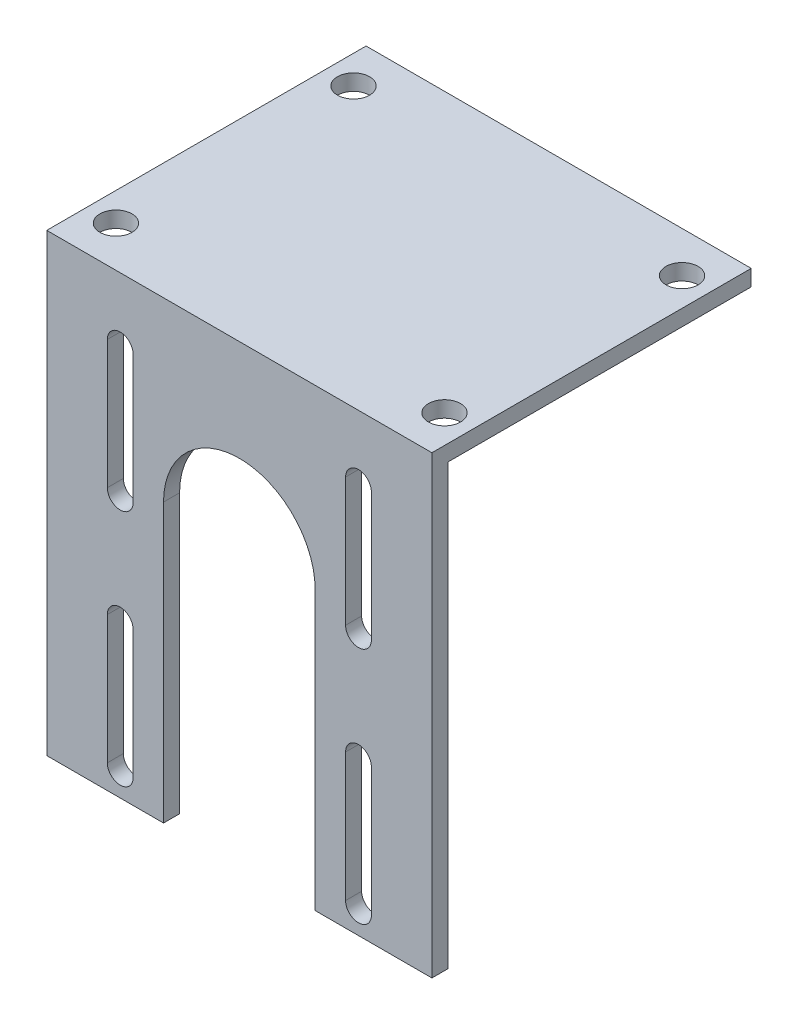
from build123d import *

# Parameters (mm, degrees)
SKETCH1_W           = 76.2
SKETCH1_H           = 100
BOSS_EXTRUDE1_DEPTH = 3.175
CUT_EXTRUDE2_REACH  = 5.175
SKETCH4_W           = 76.2
SKETCH4_H           = 3.175
BOSS_EXTRUDE2_DEPTH = 60
SKETCH5_R           = 3.175
CUT_EXTRUDE3_DEPTH  = 3.175
SKETCH6_W           = 76.2
SKETCH6_H           = 10
CUT_EXTRUDE4_DEPTH  = 64.175


with BuildPart() as part:
    # Sketch1 → Boss-Extrude1 (new body)
    with BuildSketch(Plane.XY):
        with Locations((38.1, -50)):
            Rectangle(SKETCH1_W, SKETCH1_H)
        with BuildLine():
            Line((17.08, -12.7), (17.08, -38.1))
            ThreePointArc((17.08, -38.1), (14.53, -40.65), (11.98, -38.1))
            Line((11.98, -38.1), (11.98, -12.7))
            ThreePointArc((11.98, -12.7), (14.53, -10.15), (17.08, -12.7))
        make_face(mode=Mode.SUBTRACT)
        with BuildLine():
            Line((59.12, -12.7), (59.12, -38.1))
            ThreePointArc((59.12, -38.1), (61.67, -40.65), (64.22, -38.1))
            Line((64.22, -38.1), (64.22, -12.7))
            ThreePointArc((64.22, -12.7), (61.67, -10.15), (59.12, -12.7))
        make_face(mode=Mode.SUBTRACT)
        with BuildLine():
            Line((17.08, -85.24), (17.08, -59.84))
            ThreePointArc((17.08, -59.84), (14.53, -57.29), (11.98, -59.84))
            Line((11.98, -59.84), (11.98, -85.24))
            ThreePointArc((11.98, -85.24), (14.53, -87.79), (17.08, -85.24))
        make_face(mode=Mode.SUBTRACT)
        with BuildLine():
            Line((59.12, -85.265), (59.12, -59.815))
            ThreePointArc((59.12, -59.815), (61.67, -57.265), (64.22, -59.815))
            Line((64.22, -59.815), (64.22, -85.265))
            ThreePointArc((64.22, -85.265), (61.67, -87.815), (59.12, -85.265))
        make_face(mode=Mode.SUBTRACT)
    extrude(amount=BOSS_EXTRUDE1_DEPTH)

    # Sketch2 → Cut-Extrude2 (cut, up to next)
    with BuildSketch(Plane.XY.offset(3.175), mode=Mode.PRIVATE) as cut_extrude2_sk1:
        with BuildLine():
            Line((23.1, -35), (23.1, -100))
            Line((23.1, -100), (53.1, -100))
            Line((53.1, -100), (53.1, -35))
            ThreePointArc((53.1, -35), (38.1, -20), (23.1, -35))
        make_face()
    cut_extrude2_tool1 = extrude(cut_extrude2_sk1.sketch, amount=-CUT_EXTRUDE2_REACH, mode=Mode.PRIVATE) & part.part
    add(cut_extrude2_tool1.solids().sort_by_distance((38.1, -61.536522, 3.175))[0], mode=Mode.SUBTRACT)

    # Sketch4 → Boss-Extrude2 (add)
    with BuildSketch(Plane(origin=(0, 0, 0), x_dir=(-1, 0, 0), z_dir=(0, 0, -1))):
        with Locations((-38.1, -1.5875)):
            Rectangle(SKETCH4_W, SKETCH4_H)
    extrude(amount=BOSS_EXTRUDE2_DEPTH)

    # Sketch5 → Cut-Extrude3 (cut)
    with BuildSketch(Plane(origin=(0, 0, 0), x_dir=(1, 0, 0), z_dir=(0, 1, 0))):
        with Locations((5.6, 51.9125)):
            Circle(SKETCH5_R)
        with Locations((5.6, 4.9125)):
            Circle(SKETCH5_R)
        with Locations((70.6, 51.9125)):
            Circle(SKETCH5_R)
        with Locations((70.6, 4.9125)):
            Circle(SKETCH5_R)
    extrude(amount=-CUT_EXTRUDE3_DEPTH, mode=Mode.SUBTRACT)

    # Sketch6 → Cut-Extrude4 (cut, through all)
    with BuildSketch(Plane.XY.offset(3.175)):
        with Locations((38.1, -95)):
            Rectangle(SKETCH6_W, SKETCH6_H)
    extrude(amount=-CUT_EXTRUDE4_DEPTH, mode=Mode.SUBTRACT)


solid = part.part
